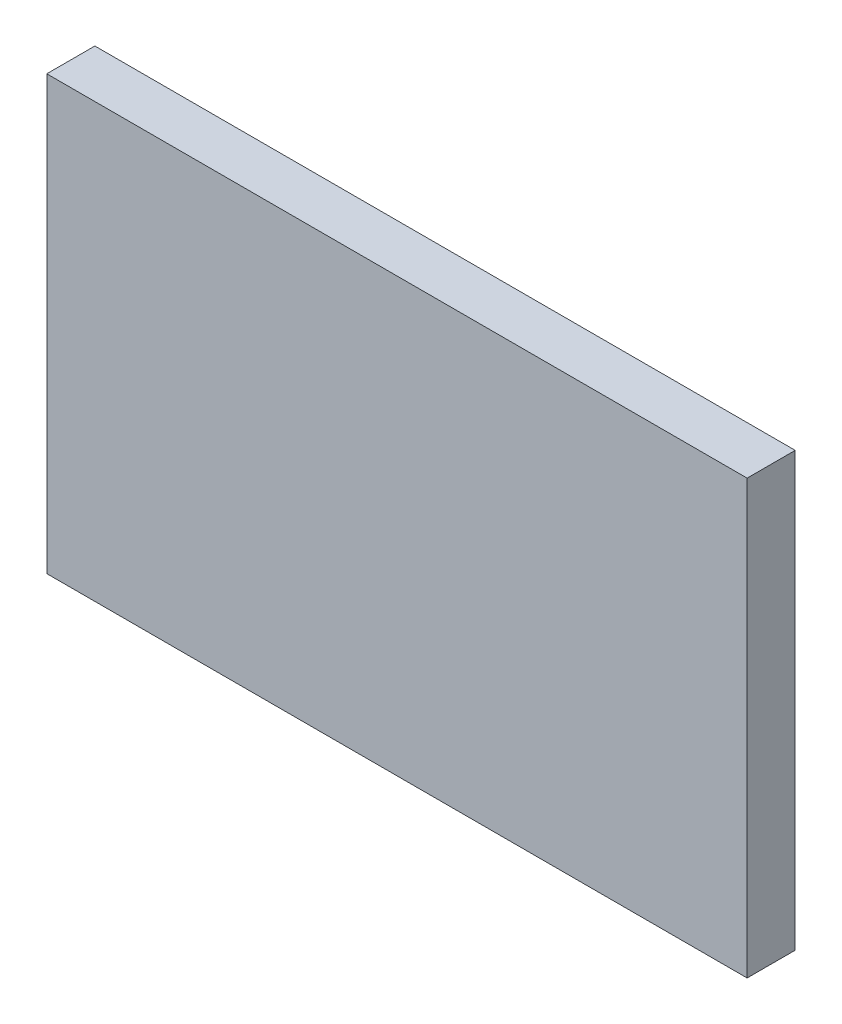
from build123d import *

# Parameters (mm, degrees)
SKETCH1_W           = 46.228
SKETCH1_H           = 28.575
BOSS_EXTRUDE1_DEPTH = 3.175


with BuildPart() as part:
    # Sketch1 → Boss-Extrude1 (new body)
    with BuildSketch(Plane.XY):
        Rectangle(SKETCH1_W, SKETCH1_H)
    extrude(amount=BOSS_EXTRUDE1_DEPTH)


solid = part.part
